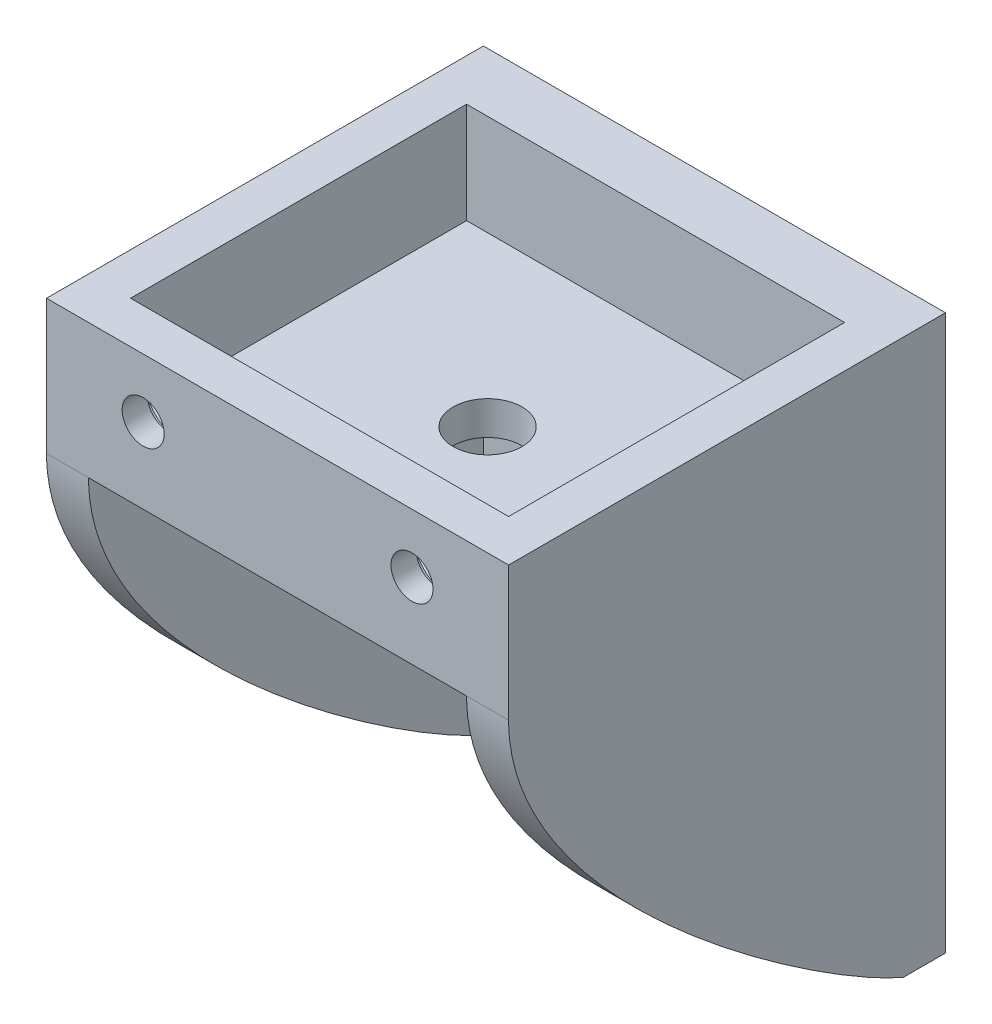
from build123d import *

# Parameters (mm, degrees)
SKETCH1_W           = 55
SKETCH1_H           = 50
SKETCH1_R           = 2.5
BOSS_EXTRUDE1_DEPTH = 5
SKETCH2_R           = 5
CUT_EXTRUDE1_DEPTH  = 2
SKETCH3_W           = 55
SKETCH3_H           = 52
BOSS_EXTRUDE2_DEPTH = 16
SKETCH4_R           = 4.1
CUT_EXTRUDE2_DEPTH  = 17
BOSS_EXTRUDE3_DEPTH = 5
SKETCH6_W           = 45
SKETCH6_H           = 40
CUT_EXTRUDE3_DEPTH  = 12
SKETCH8_R           = 2.5
CUT_EXTRUDE5_DEPTH  = 5
SKETCH10_R          = 5
CUT_EXTRUDE6_DEPTH  = 2


with BuildPart() as part:
    # Sketch1 → Boss-Extrude1 (new body)
    with BuildSketch(Plane.XY):
        Rectangle(SKETCH1_W, SKETCH1_H)
        with Locations((-17.5, -15)):
            Circle(SKETCH1_R, mode=Mode.SUBTRACT)
        with Locations((17.5, -15)):
            Circle(SKETCH1_R, mode=Mode.SUBTRACT)
        with Locations((17.5, 15)):
            Circle(SKETCH1_R, mode=Mode.SUBTRACT)
        with Locations((-17.5, 15)):
            Circle(SKETCH1_R, mode=Mode.SUBTRACT)
    extrude(amount=BOSS_EXTRUDE1_DEPTH)

    # Sketch2 → Cut-Extrude1 (cut)
    with BuildSketch(Plane.XY.offset(5)):
        with Locations((-17.5, -15)):
            Circle(SKETCH2_R)
        with Locations((17.5, -15)):
            Circle(SKETCH2_R)
        with Locations((-17.5, 15)):
            Circle(SKETCH2_R)
        with Locations((17.5, 15)):
            Circle(SKETCH2_R)
    extrude(amount=-CUT_EXTRUDE1_DEPTH, mode=Mode.SUBTRACT)

    # Sketch3 → Boss-Extrude2 (add)
    with BuildSketch(Plane(origin=(0, 25, 0), x_dir=(1, 0, 0), z_dir=(0, 1, 0))):
        with Locations((0, -26)):
            Rectangle(SKETCH3_W, SKETCH3_H)
    extrude(amount=BOSS_EXTRUDE2_DEPTH)

    # Sketch4 → Cut-Extrude2 (cut, through all)
    with BuildSketch(Plane(origin=(0, 25, 0), x_dir=(-1, 0, 0), z_dir=(0, -1, 0))):
        with Locations((0, -27)):
            Circle(SKETCH4_R)
    extrude(amount=-CUT_EXTRUDE2_DEPTH, mode=Mode.SUBTRACT)

    # Sketch5 → Boss-Extrude3 (add)
    with BuildSketch(Plane.ZY.offset(27.5)):
        with BuildLine():
            Line((5, -25), (5, 25))
            Line((5, 25), (52, 25))
            add(Edge.make_bspline(
                [(52, 25), (52, 4.232970162), (15.26663468, -20.719918254), (5, -25)],
                knots=[0, 0, 0, 0, 0.911487557, 0.911487557, 0.911487557, 0.911487557], degree=3))
        make_face()
    boss_extrude3 = extrude(amount=-BOSS_EXTRUDE3_DEPTH)

    # Mirror1: Boss-Extrude3 across plane
    add(boss_extrude3.mirror(Plane(origin=(0, 0, 0), x_dir=(0, 0, 1), z_dir=(1, 0, 0))))

    # Sketch6 → Cut-Extrude3 (cut)
    with BuildSketch(Plane(origin=(0, 41, 0), x_dir=(1, 0, 0), z_dir=(0, 1, 0))):
        with Locations((0, -27)):
            Rectangle(SKETCH6_W, SKETCH6_H)
    extrude(amount=-CUT_EXTRUDE3_DEPTH, mode=Mode.SUBTRACT)

    # Sketch8 → Cut-Extrude5 (cut)
    with BuildSketch(Plane.XY.offset(52)):
        with Locations((16, 34)):
            Circle(SKETCH8_R)
        with Locations((-16, 34)):
            Circle(SKETCH8_R)
    extrude(amount=-CUT_EXTRUDE5_DEPTH, mode=Mode.SUBTRACT)

    # Sketch10 → Cut-Extrude6 (cut)
    with BuildSketch(Plane(origin=(0, 0, 47), x_dir=(-1, 0, 0), z_dir=(0, 0, -1))):
        with Locations((-16, 34)):
            Circle(SKETCH10_R)
        with Locations((16, 34)):
            Circle(SKETCH10_R)
    extrude(amount=-CUT_EXTRUDE6_DEPTH, mode=Mode.SUBTRACT)


solid = part.part
